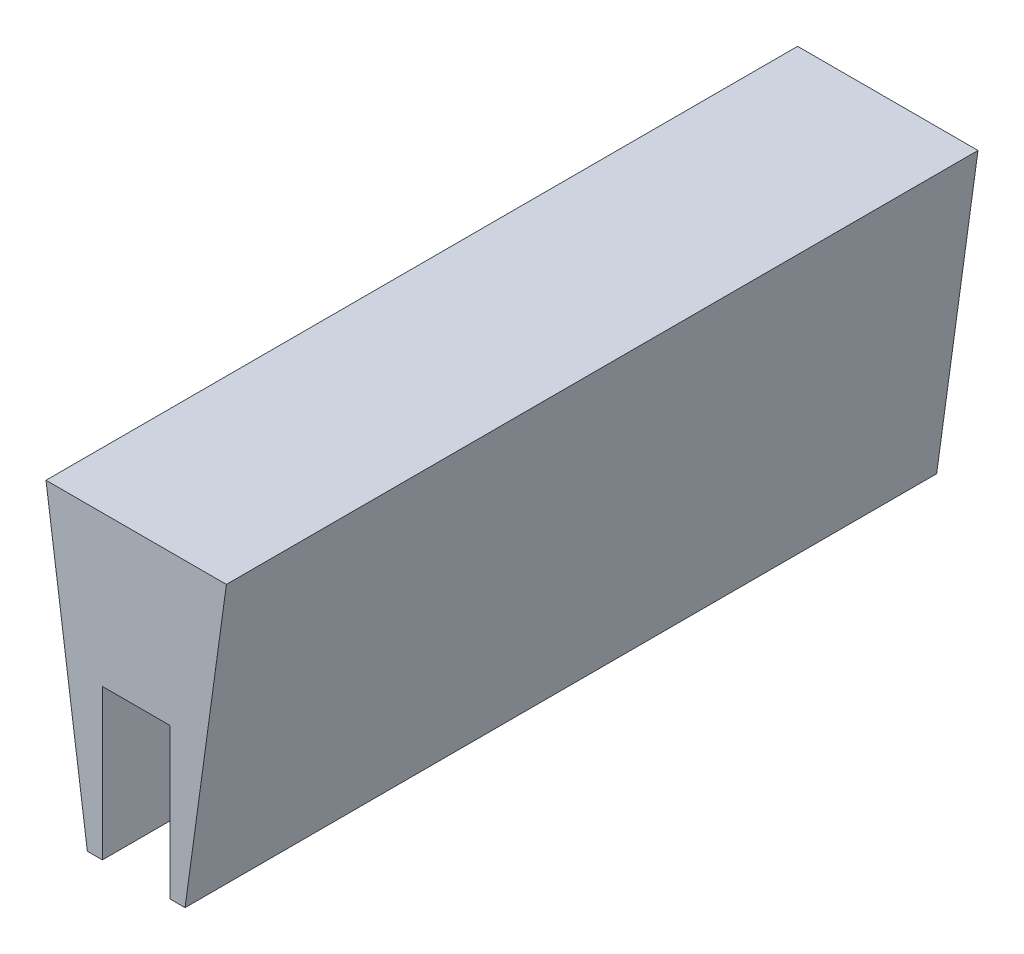
from build123d import *

# Parameters (mm, degrees)
BOSS_EXTRUDE1_DEPTH = 50


with BuildPart() as part:
    # Sketch1 → Boss-Extrude1 (new body)
    with BuildSketch(Plane.XY):
        Polygon((-6, 20), (6, 20), (3.25, 0), (2.25, 0), (2.25, 10), (-2.25, 10), (-2.25, 0), (-3.25, 0), align=None)
    extrude(amount=BOSS_EXTRUDE1_DEPTH)


solid = part.part
